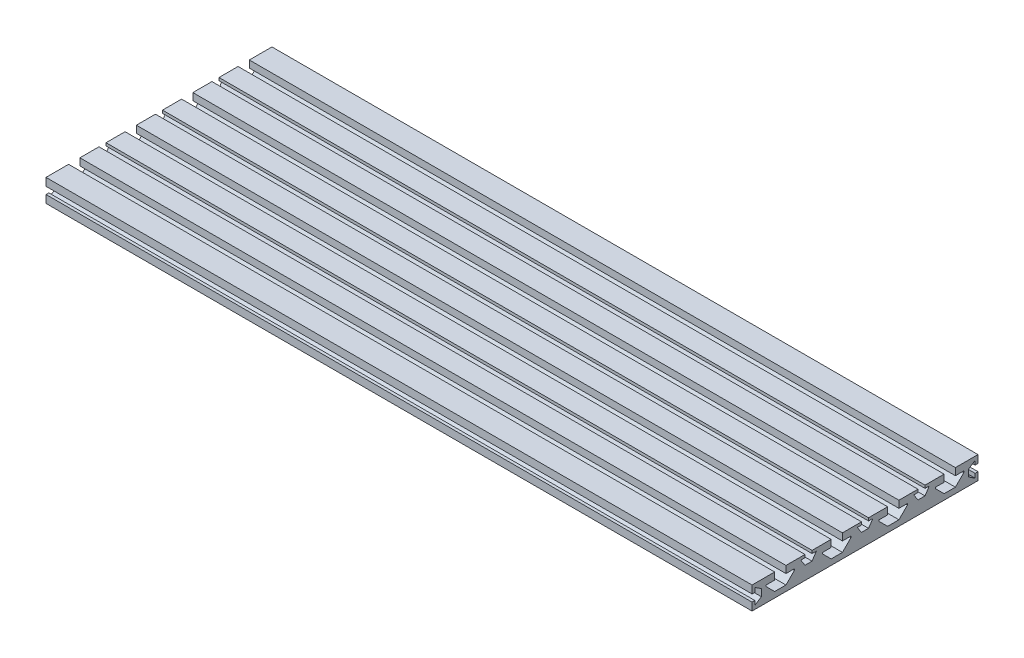
from build123d import *

# Parameters (mm, degrees)
BOSS_EXTRUDE1_DEPTH = 500


with BuildPart() as part:
    # Sketch1 → Boss-Extrude1 (new body)
    with BuildSketch(Plane(origin=(0, 0, 0), x_dir=(0, 0, -1), z_dir=(1, 0, 0))):
        Polygon((80, -7.273459567), (-80, -7.273459567), (-80, -1.773459567), (-78, -1.773459567), (-78, -4.773459567), (-73.396138399, -1.773459567), (-73.396138399, 3.226540433), (-78, 6.226540433), (-78, 3.226540433), (-80, 3.226540433), (-80, 8.726540433), (-64, 8.726540433), (-64, 3.726540433), (-70, 3.726540433), (-70, 2.726540433), (-64, -3.273459567), (-56, -3.273459567), (-50, 2.726540433), (-50, 3.726540433), (-56, 3.726540433), (-56, 8.726540433), (-42.5, 8.726540433), (-42.5, 6.726540433), (-45.5, 6.726540433), (-42.5, 2.122678831), (-37.5, 2.122678831), (-34.5, 6.726540433), (-37.5, 6.726540433), (-37.5, 8.726540433), (-24, 8.726540433), (-24, 3.726540433), (-30, 3.726540433), (-30, 2.726540433), (-24, -3.273459567), (-16, -3.273459567), (-10, 2.726540433), (-10, 3.726540433), (-16, 3.726540433), (-16, 8.726540433), (-2.5, 8.726540433), (-2.5, 6.726540433), (-5.5, 6.726540433), (-2.5, 2.226540433), (2.5, 2.226540433), (5.5, 6.726540433), (2.5, 6.726540433), (2.5, 8.726540433), (16, 8.726540433), (16, 3.726540433), (10, 3.726540433), (10, 2.726540433), (16, -3.273459567), (24, -3.273459567), (30, 2.726540433), (30, 3.726540433), (24, 3.726540433), (24, 8.726540433), (37.5, 8.726540433), (37.5, 6.726540433), (34.5, 6.726540433), (37.5, 2.122678831), (42.5, 2.122678831), (45.5, 6.726540433), (42.5, 6.726540433), (42.5, 8.726540433), (56, 8.726540433), (56, 3.726540433), (50, 3.726540433), (50, 2.726540433), (56, -3.273459567), (64, -3.273459567), (70, 2.726540433), (70, 3.726540433), (64, 3.726540433), (64, 8.726540433), (80, 8.726540433), (80, 3.226540433), (78, 3.226540433), (78, 6.226540433), (73.396138399, 3.226540433), (73.396138399, -1.773459567), (78, -4.773459567), (78, -1.773459567), (80, -1.773459567), align=None)
    extrude(amount=BOSS_EXTRUDE1_DEPTH)


solid = part.part
